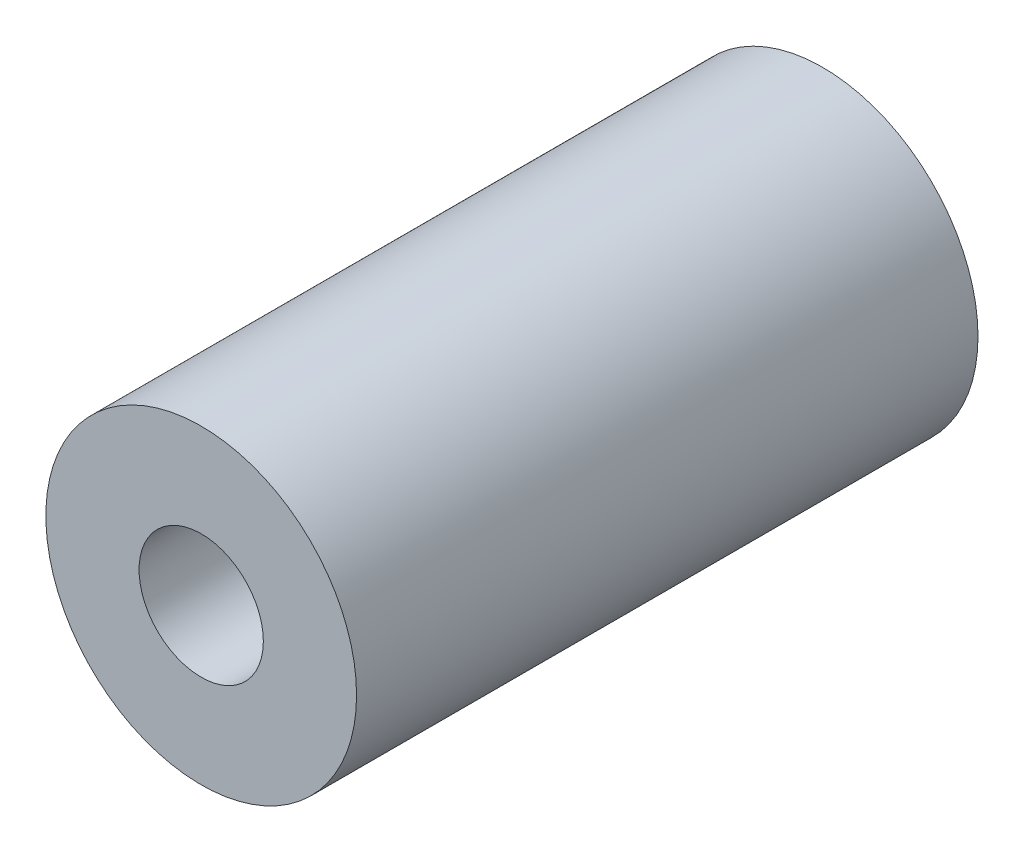
from build123d import *

# Parameters (mm, degrees)
SKETCH1_R           = 5
SKETCH1_R_2         = 2
BOSS_EXTRUDE1_DEPTH = 10


with BuildPart() as part:
    # Sketch1 → Boss-Extrude1 (new body, symmetric)
    with BuildSketch(Plane.XY):
        Circle(SKETCH1_R)
        Circle(SKETCH1_R_2, mode=Mode.SUBTRACT)
    extrude(amount=BOSS_EXTRUDE1_DEPTH, both=True)


solid = part.part
